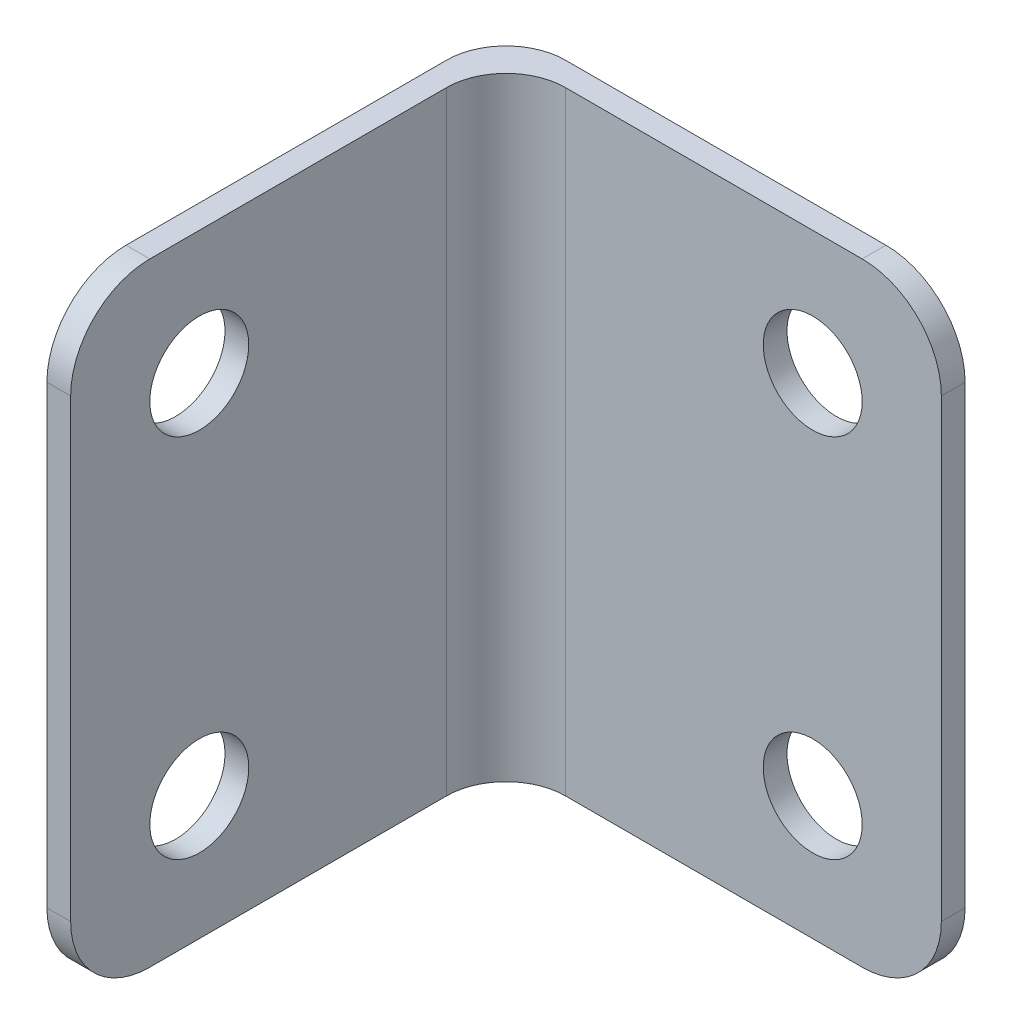
from build123d import *

# Parameters (mm, degrees)
EXTRUDE_1_DEPTH     = 31
SKETCH_2_R          = 2.5
CUT_EXTRUDE_1_DEPTH = 30.5
SKETCH_4_R          = 2.5
CUT_EXTRUDE_2_DEPTH = 30.5


with BuildPart() as part:
    # 草图1 → 凸台-拉伸1 (new body)
    with BuildSketch(Plane(origin=(0, 0, 0), x_dir=(1, 0, 0), z_dir=(0, 1, 0))):
        with BuildLine():
            Line((3, 0), (23.2, 0))
            Line((23.2, 0), (23.2, -1.2))
            Line((23.2, -1.2), (4.2, -1.2))
            ThreePointArc((4.2, -1.2), (2.078679656, -2.078679656), (1.2, -4.2))
            Line((1.2, -4.2), (1.2, -23.2))
            Line((1.2, -23.2), (0, -23.2))
            Line((0, -23.2), (0, -3))
            ThreePointArc((0, -3), (0.878679656, -0.878679656), (3, 0))
        make_face()
    extrude(amount=EXTRUDE_1_DEPTH)

    # 草图2 → 切除-拉伸1 (cut)
    with BuildSketch(Plane.XY.offset(1.2)):
        with BuildLine():
            ThreePointArc((19.2, 31), (22.028427125, 29.828427125), (23.2, 27))
            Line((23.2, 27), (23.2, 31))
            Line((23.2, 31), (19.2, 31))
        make_face()
        with Locations((16.7, 24.75)):
            Circle(SKETCH_2_R)
        with BuildLine():
            Line((23.2, 0), (23.2, 4))
            ThreePointArc((23.2, 4), (22.028427125, 1.171572875), (19.2, 0))
            Line((19.2, 0), (23.2, 0))
        make_face()
        with Locations((16.7, 6.25)):
            Circle(SKETCH_2_R)
    extrude(amount=-CUT_EXTRUDE_1_DEPTH, mode=Mode.SUBTRACT)

    # 草图4 → 切除-拉伸2 (cut)
    with BuildSketch(Plane(origin=(1.2, 0, 1), x_dir=(0, 0, -1), z_dir=(1, 0, 0))):
        with Locations((-15.7, 6.25)):
            Circle(SKETCH_4_R)
        with BuildLine():
            ThreePointArc((-18.2, 0), (-21.028427125, 1.171572875), (-22.2, 4))
            Line((-22.2, 4), (-22.2, 0))
            Line((-22.2, 0), (-18.2, 0))
        make_face()
        with BuildLine():
            Line((-22.2, 31), (-22.2, 27))
            ThreePointArc((-22.2, 27), (-21.028427125, 29.828427125), (-18.2, 31))
            Line((-18.2, 31), (-22.2, 31))
        make_face()
        with Locations((-15.7, 24.75)):
            Circle(SKETCH_4_R)
    extrude(amount=-CUT_EXTRUDE_2_DEPTH, mode=Mode.SUBTRACT)


solid = part.part
